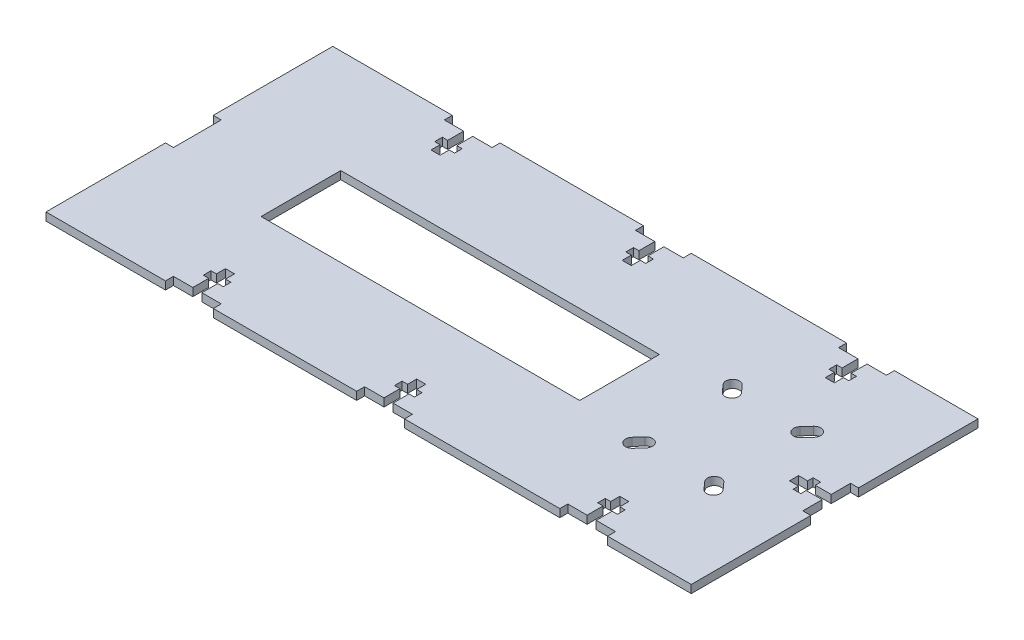
from build123d import *

# Parameters (mm, degrees)
BOSS_EXTRUDE1_DEPTH = 2.54
CUT_EXTRUDE1_REACH  = 4.54
CUT_EXTRUDE2_REACH  = 4.54
SKETCH4_W           = 101.6
SKETCH4_H           = 25.4


with BuildPart() as part:
    # Sketch2 → Boss-Extrude1 (new body)
    with BuildSketch(Plane(origin=(0, 0, 0), x_dir=(1, 0, 0), z_dir=(0, 1, 0))):
        Polygon((-102.87, -45.72), (-64.77, -45.72), (-64.77, -43.18), (-58.5978, -43.18), (-58.5978, -38.1), (-60.325, -38.1), (-60.325, -35.66795), (-58.5978, -35.66795), (-58.5978, -32.766), (-55.7022, -32.766), (-55.7022, -35.66795), (-53.975, -35.66795), (-53.975, -38.1), (-55.7022, -38.1), (-55.7022, -43.18), (-49.53, -43.18), (-49.53, -45.72), (-3.81, -45.72), (-3.81, -43.18), (2.3622, -43.18), (2.3622, -38.1), (0.635, -38.1), (0.635, -35.66795), (2.3622, -35.66795), (2.3622, -32.766), (5.2578, -32.766), (5.2578, -35.66795), (6.985, -35.66795), (6.985, -38.1), (5.2578, -38.1), (5.2578, -43.18), (11.43, -43.18), (11.43, -45.72), (60.96, -45.72), (60.96, -43.18), (67.1322, -43.18), (67.1322, -38.1), (65.405, -38.1), (65.405, -35.66795), (67.1322, -35.66795), (67.1322, -32.766), (70.0278, -32.766), (70.0278, -35.66795), (71.755, -35.66795), (71.755, -38.1), (70.0278, -38.1), (70.0278, -43.18), (76.2, -43.18), (76.2, -45.72), (102.87, -45.72), (102.87, -7.62), (100.33, -7.62), (100.33, -1.4478), (95.25, -1.4478), (95.25, -3.175), (92.81795, -3.175), (92.81795, -1.4478), (89.916, -1.4478), (89.916, 1.4478), (92.81795, 1.4478), (92.81795, 3.175), (95.25, 3.175), (95.25, 1.4478), (100.33, 1.4478), (100.33, 7.62), (102.87, 7.62), (102.87, 45.72), (76.2, 45.72), (76.2, 43.18), (70.0278, 43.18), (70.0278, 38.1), (71.755, 38.1), (71.755, 35.66795), (70.0278, 35.66795), (70.0278, 32.766), (67.1322, 32.766), (67.1322, 35.66795), (65.405, 35.66795), (65.405, 38.1), (67.1322, 38.1), (67.1322, 43.18), (60.96, 43.18), (60.96, 45.72), (11.43, 45.72), (11.43, 43.18), (5.2578, 43.18), (5.2578, 38.1), (6.985, 38.1), (6.985, 35.66795), (5.2578, 35.66795), (5.2578, 32.766), (2.3622, 32.766), (2.3622, 35.66795), (0.635, 35.66795), (0.635, 38.1), (2.3622, 38.1), (2.3622, 43.18), (-3.81, 43.18), (-3.81, 45.72), (-49.53, 45.72), (-49.53, 43.18), (-55.7022, 43.18), (-55.7022, 38.1), (-53.975, 38.1), (-53.975, 35.66795), (-55.7022, 35.66795), (-55.7022, 32.766), (-58.5978, 32.766), (-58.5978, 35.66795), (-60.325, 35.66795), (-60.325, 38.1), (-58.5978, 38.1), (-58.5978, 43.18), (-64.77, 43.18), (-64.77, 45.72), (-102.87, 45.72), (-102.87, 7.62), (-100.33, 7.62), (-100.33, -7.62), (-102.87, -7.62), align=None)
    extrude(amount=-BOSS_EXTRUDE1_DEPTH)

    # Sketch3 → Cut-Extrude1 (cut, up to next)
    with BuildSketch(Plane(origin=(0, 0, 0), x_dir=(1, 0, 0), z_dir=(0, 1, 0)), mode=Mode.PRIVATE) as cut_extrude1_sk1:
        with BuildLine():
            Line((81.873223588, 14.562666667), (79.841223588, 12.290821602))
            ThreePointArc((79.841223588, 12.290821602), (76.792666667, 12.120931347), (76.622776412, 15.169488268))
            Line((76.622776412, 15.169488268), (78.654776412, 17.441333333))
            ThreePointArc((78.654776412, 17.441333333), (81.703333333, 17.611223588), (81.873223588, 14.562666667))
        make_face()
    cut_extrude1_tool1 = extrude(cut_extrude1_sk1.sketch, amount=-CUT_EXTRUDE1_REACH, mode=Mode.PRIVATE) & part.part
    add(cut_extrude1_tool1.solids().sort_by_distance((79.248, 0, -14.866077))[0], mode=Mode.SUBTRACT)
    # Sketch3 → Cut-Extrude1 (cut, up to next)
    with BuildSketch(Plane(origin=(0, 0, 0), x_dir=(1, 0, 0), z_dir=(0, 1, 0)), mode=Mode.PRIVATE) as cut_extrude1_sk2:
        with BuildLine():
            Line((52.746776412, 14.562666667), (54.778776412, 12.290821602))
            ThreePointArc((54.778776412, 12.290821602), (57.827333333, 12.120931347), (57.997223588, 15.169488268))
            Line((57.997223588, 15.169488268), (55.965223588, 17.441333333))
            ThreePointArc((55.965223588, 17.441333333), (52.916666667, 17.611223588), (52.746776412, 14.562666667))
        make_face()
    cut_extrude1_tool2 = extrude(cut_extrude1_sk2.sketch, amount=-CUT_EXTRUDE1_REACH, mode=Mode.PRIVATE) & part.part
    add(cut_extrude1_tool2.solids().sort_by_distance((55.372, 0, -14.866077))[0], mode=Mode.SUBTRACT)
    # Sketch3 → Cut-Extrude1 (cut, up to next)
    with BuildSketch(Plane(origin=(0, 0, 0), x_dir=(1, 0, 0), z_dir=(0, 1, 0)), mode=Mode.PRIVATE) as cut_extrude1_sk3:
        with BuildLine():
            Line((81.873223588, -14.562666667), (79.841223588, -12.290821602))
            ThreePointArc((79.841223588, -12.290821602), (76.792666667, -12.120931347), (76.622776412, -15.169488268))
            Line((76.622776412, -15.169488268), (78.654776412, -17.441333333))
            ThreePointArc((78.654776412, -17.441333333), (81.703333333, -17.611223588), (81.873223588, -14.562666667))
        make_face()
    cut_extrude1_tool3 = extrude(cut_extrude1_sk3.sketch, amount=-CUT_EXTRUDE1_REACH, mode=Mode.PRIVATE) & part.part
    add(cut_extrude1_tool3.solids().sort_by_distance((79.248, 0, 14.866077))[0], mode=Mode.SUBTRACT)
    # Sketch3 → Cut-Extrude1 (cut, up to next)
    with BuildSketch(Plane(origin=(0, 0, 0), x_dir=(1, 0, 0), z_dir=(0, 1, 0)), mode=Mode.PRIVATE) as cut_extrude1_sk4:
        with BuildLine():
            Line((52.746776412, -14.562666667), (54.778776412, -12.290821602))
            ThreePointArc((54.778776412, -12.290821602), (57.827333333, -12.120931347), (57.997223588, -15.169488268))
            Line((57.997223588, -15.169488268), (55.965223588, -17.441333333))
            ThreePointArc((55.965223588, -17.441333333), (52.916666667, -17.611223588), (52.746776412, -14.562666667))
        make_face()
    cut_extrude1_tool4 = extrude(cut_extrude1_sk4.sketch, amount=-CUT_EXTRUDE1_REACH, mode=Mode.PRIVATE) & part.part
    add(cut_extrude1_tool4.solids().sort_by_distance((55.372, 0, 14.866077))[0], mode=Mode.SUBTRACT)

    # Sketch4 → Cut-Extrude2 (cut, up to next)
    with BuildSketch(Plane(origin=(0, 0, 0), x_dir=(1, 0, 0), z_dir=(0, 1, 0)), mode=Mode.PRIVATE) as cut_extrude2_sk1:
        with Locations((-16.51, 0)):
            Rectangle(SKETCH4_W, SKETCH4_H)
    cut_extrude2_tool1 = extrude(cut_extrude2_sk1.sketch, amount=-CUT_EXTRUDE2_REACH, mode=Mode.PRIVATE) & part.part
    add(cut_extrude2_tool1.solids().sort_by_distance((-16.51, 0, 0))[0], mode=Mode.SUBTRACT)


solid = part.part
